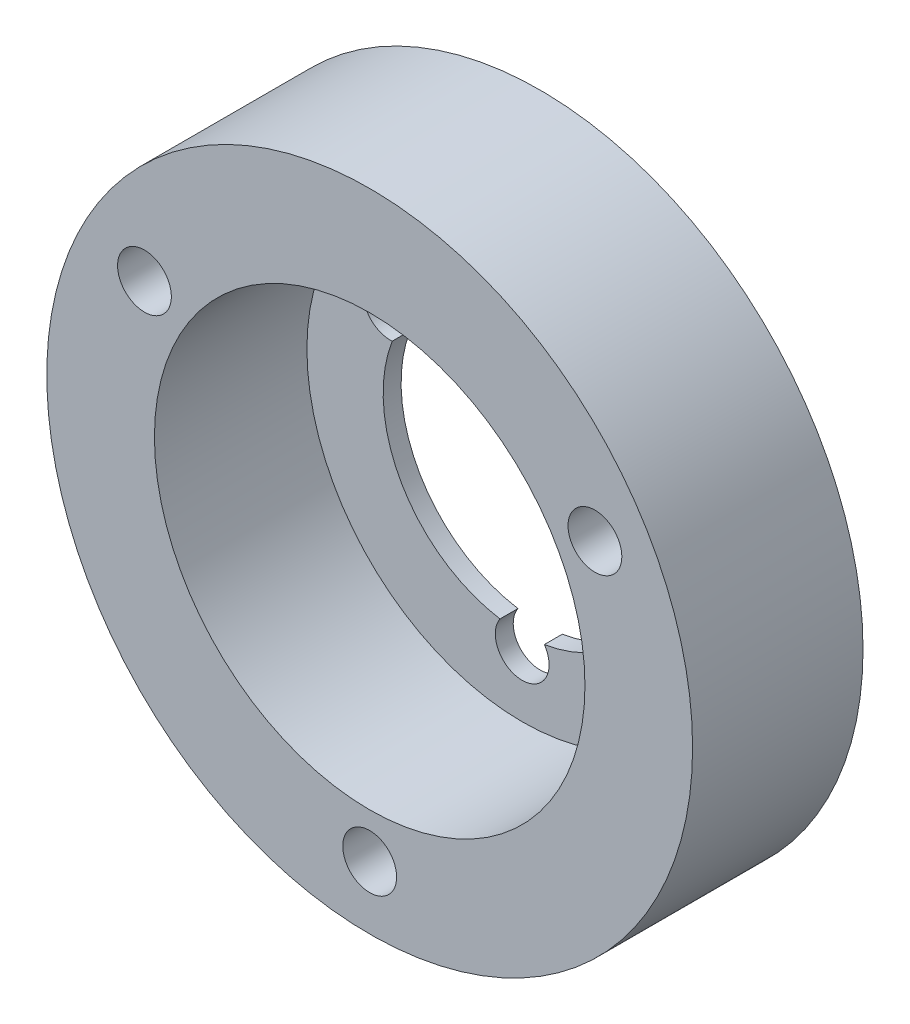
from build123d import *

# Parameters (mm, degrees)
ESQUISSE1_W      = 50
ESQUISSE1_H      = 9.5
EXTRUSION1_DEPTH = 45
ESQUISSE2_R      = 1.5
EXTRUSION2_DEPTH = 45
ESQUISSE3_R      = 12
EXTRUSION3_DEPTH = 8.5
ESQUISSE4_R      = 36.120283588
ESQUISSE4_R_2    = 18
EXTRUSION4_DEPTH = 10.5


with BuildPart() as part:
    # Esquisse1 → Extrusion1 (new body)
    with BuildSketch(Plane(origin=(0, 0, 0), x_dir=(1, 0, 0), z_dir=(0, 1, 0))):
        with Locations((25, -4.75)):
            Rectangle(ESQUISSE1_W, ESQUISSE1_H)
    extrude(amount=EXTRUSION1_DEPTH)

    # Esquisse2 → Extrusion2 (cut)
    with BuildSketch(Plane.XY.offset(9.5)):
        with Locations((12.445, 29.74863263)):
            Circle(ESQUISSE2_R)
        with Locations((37.555, 29.74863263)):
            Circle(ESQUISSE2_R)
        with Locations((25, 8.002734741)):
            Circle(ESQUISSE2_R)
        with BuildLine():
            ThreePointArc((17.756055836, 25.254591249), (16.339745962, 27.5), (18.992481919, 27.396144045))
            ThreePointArc((18.992481919, 27.396144045), (25, 30.25), (31.007518081, 27.396144045))
            ThreePointArc((31.007518081, 27.396144045), (33.660254038, 27.5), (32.243944164, 25.254591249))
            ThreePointArc((32.243944164, 25.254591249), (31.711696879, 18.625), (26.236426083, 14.849264706))
            ThreePointArc((26.236426083, 14.849264706), (25, 12.5), (23.763573917, 14.849264706))
            ThreePointArc((23.763573917, 14.849264706), (18.288303121, 18.625), (17.756055836, 25.254591249))
        make_face()
    extrude(amount=-EXTRUSION2_DEPTH, mode=Mode.SUBTRACT)

    # Esquisse3 → Extrusion3 (cut)
    with BuildSketch(Plane.XY.offset(9.5)):
        with Locations((25, 22.5)):
            Circle(ESQUISSE3_R)
    extrude(amount=-EXTRUSION3_DEPTH, mode=Mode.SUBTRACT)

    # Esquisse4 → Extrusion4 (cut, through all)
    with BuildSketch(Plane.XY.offset(9.5)):
        with Locations((25, 22.5)):
            Circle(ESQUISSE4_R)
        with Locations((25, 22.5)):
            Circle(ESQUISSE4_R_2, mode=Mode.SUBTRACT)
    extrude(amount=-EXTRUSION4_DEPTH, mode=Mode.SUBTRACT)


solid = part.part
